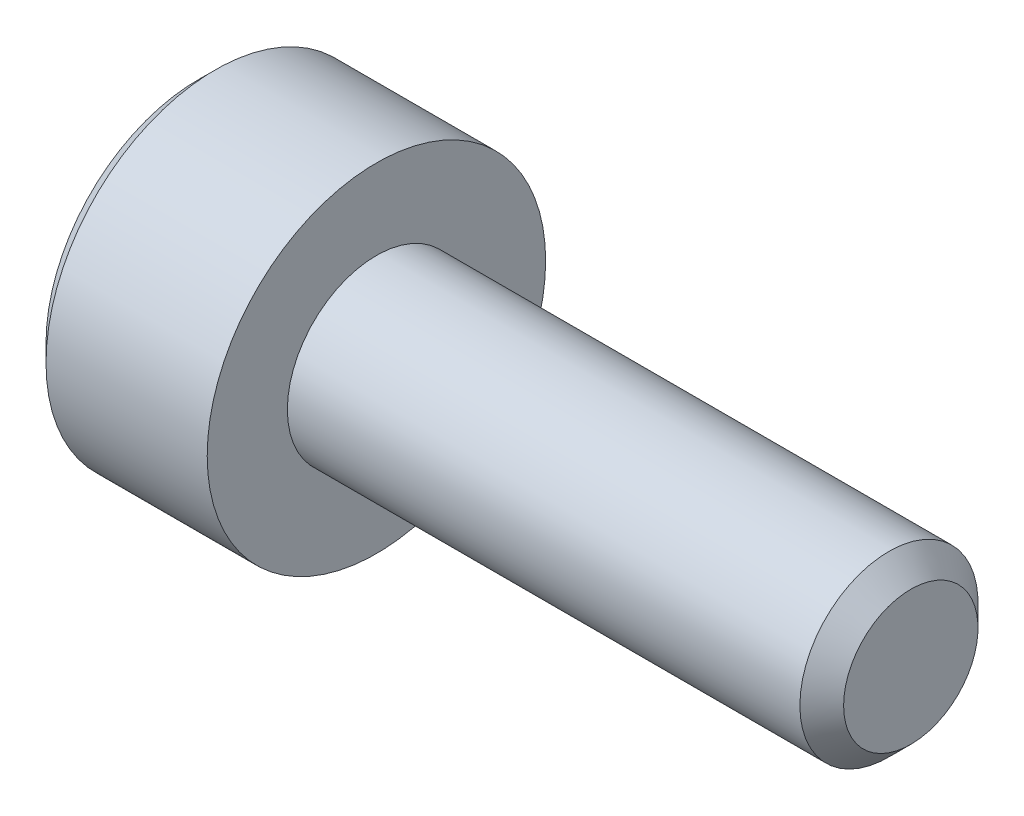
from build123d import *

# Parameters (mm, degrees)
CUT_EXTRUDE1_DEPTH = 0.8


with BuildPart() as part:
    # Sketch1 → Revolve1 (revolve)
    with BuildSketch(Plane.XY):
        Polygon((-2, 0), (-2, 1.71), (-1.81, 1.9), (0, 1.9), (0, 1), (5.7545, 1), (6, 0.7545), (6, 0), align=None)
    revolve(axis=Axis((6, 0, 0), (-1, 0, 0)))

    # Sketch2 → Cut-Extrude1 (cut)
    with BuildSketch(Plane(origin=(-2, 0, 0), x_dir=(0, 0, -1), z_dir=(1, 0, 0))):
        Polygon((-0.75, -0.433012702), (0, -0.866025404), (0.75, -0.433012702), (0.75, 0.433012702), (0, 0.866025404), (-0.75, 0.433012702), align=None)
    extrude(amount=CUT_EXTRUDE1_DEPTH, mode=Mode.SUBTRACT)


solid = part.part
